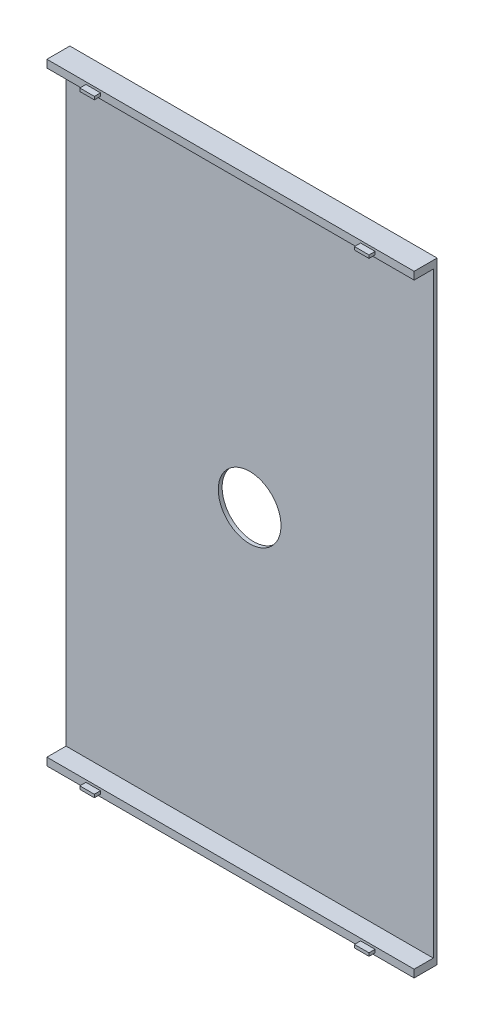
from build123d import *

# Parameters (mm, degrees)
SKETCH2_W           = 48
SKETCH2_H           = 80
BOSS_EXTRUDE1_DEPTH = 0.5
SKETCH3_W           = 48
SKETCH3_H           = 1
BOSS_EXTRUDE2_DEPTH = 2.5
SKETCH4_W           = 1.9
SKETCH4_H           = 0.4
BOSS_EXTRUDE3_DEPTH = 0.8
SKETCH5_W           = 1.9
SKETCH5_H           = 0.4
BOSS_EXTRUDE4_DEPTH = 0.8
SKETCH6_R           = 4.1
CUT_EXTRUDE2_DEPTH  = 0.5


with BuildPart() as part:
    # Sketch2 → Boss-Extrude1 (new body)
    with BuildSketch(Plane.XY):
        with Locations((24, 40)):
            Rectangle(SKETCH2_W, SKETCH2_H)
    extrude(amount=BOSS_EXTRUDE1_DEPTH)

    # Sketch3 → Boss-Extrude2 (add)
    with BuildSketch(Plane.XY.offset(0.5)):
        with Locations((24, 79.5)):
            Rectangle(SKETCH3_W, SKETCH3_H)
        with Locations((24, 0.5)):
            Rectangle(SKETCH3_W, SKETCH3_H)
    extrude(amount=BOSS_EXTRUDE2_DEPTH)

    # Sketch4 → Boss-Extrude3 (add)
    with BuildSketch(Plane.XY.offset(3)):
        with Locations((6.05, 79.5)):
            Rectangle(SKETCH4_W, SKETCH4_H)
        with Locations((41.95, 79.5)):
            Rectangle(SKETCH4_W, SKETCH4_H)
    extrude(amount=BOSS_EXTRUDE3_DEPTH)

    # Sketch5 → Boss-Extrude4 (add)
    with BuildSketch(Plane.XY.offset(3)):
        with Locations((6.05, 0.5)):
            Rectangle(SKETCH5_W, SKETCH5_H)
        with Locations((41.95, 0.5)):
            Rectangle(SKETCH5_W, SKETCH5_H)
    extrude(amount=BOSS_EXTRUDE4_DEPTH)

    # Sketch6 → Cut-Extrude2 (cut)
    with BuildSketch(Plane(origin=(0, 0, 0), x_dir=(-1, 0, 0), z_dir=(0, 0, -1))):
        with Locations((-24, 40)):
            Circle(SKETCH6_R)
    extrude(amount=-CUT_EXTRUDE2_DEPTH, mode=Mode.SUBTRACT)


solid = part.part
